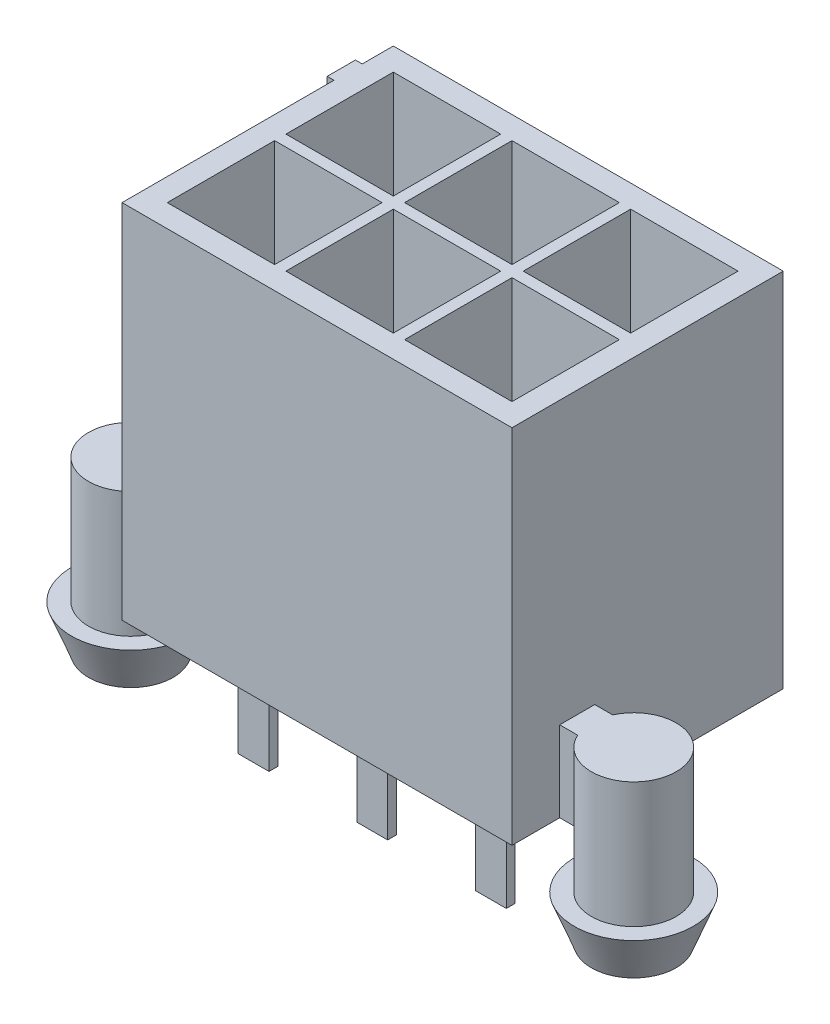
from build123d import *

# Parameters (mm, degrees)
BOSS_EXTRUDE1_DEPTH = 12.8
BOSS_EXTRUDE2_DEPTH = 2.85
SKETCH5_R           = 1.5
BOSS_EXTRUDE3_DEPTH = 3.16
SKETCH6_R           = 1.5
BOSS_EXTRUDE4_DEPTH = 1.5725
BOSS_EXTRUDE4_TAPER = -21
SKETCH9_W           = 3.8
SKETCH9_H           = 3.8
CUT_EXTRUDE3_DEPTH  = 9.2
SKETCH10_W          = 1.09
SKETCH10_H          = 1.09
BOSS_EXTRUDE6_DEPTH = 13.1
SKETCH11_W          = 3
SKETCH11_H          = 3
BOSS_EXTRUDE7_DEPTH = 1.4
CUT_EXTRUDE4_DEPTH  = 3
CUT_EXTRUDE5_DEPTH  = 1.1
LPATTERN1_COUNT     = 3
LPATTERN1_PITCH     = 4.2


with BuildPart() as part:
    # Sketch3 → Boss-Extrude1 (new body)
    with BuildSketch(Plane(origin=(0, 0, 0), x_dir=(1, 0, 0), z_dir=(0, 1, 0))):
        Polygon((13.8, 9.6), (0, 9.6), (0, 8.5), (-0.24, 8.5), (-0.24, 7.5), (0, 7.5), (0, 0), (13.8, 0), align=None)
    extrude(amount=BOSS_EXTRUDE1_DEPTH)

    # Sketch4 → Boss-Extrude2 (add)
    with BuildSketch(Plane(origin=(0, 2.85, 0), x_dir=(1, 0, 0), z_dir=(0, 1, 0))):
        with BuildLine():
            Line((0, 2.93008), (0, 1.68992))
            Line((0, 1.68992), (-0.634167, 1.68992))
            ThreePointArc((-0.634167, 1.68992), (-3.5, 2.31), (-0.634167, 2.93008))
            Line((-0.634167, 2.93008), (0, 2.93008))
        make_face()
        with BuildLine():
            Line((13.8, 2.93008), (13.8, 1.68992))
            Line((13.8, 1.68992), (14.434167, 1.68992))
            ThreePointArc((14.434167, 1.68992), (17.3, 2.31), (14.434167, 2.93008))
            Line((14.434167, 2.93008), (13.8, 2.93008))
        make_face()
    extrude(amount=-BOSS_EXTRUDE2_DEPTH)

    # Sketch5 → Boss-Extrude3 (add)
    with BuildSketch(Plane.XZ):
        with Locations((-2, -2.31)):
            Circle(SKETCH5_R)
        with Locations((15.8, -2.31)):
            Circle(SKETCH5_R)
    extrude(amount=BOSS_EXTRUDE3_DEPTH)

    # Sketch6 → Boss-Extrude4 (add)
    with BuildSketch(Plane.XZ.offset(3.16)):
        with Locations((-2, -2.31)):
            Circle(SKETCH6_R)
        with Locations((15.8, -2.31)):
            Circle(SKETCH6_R)
    extrude(amount=-BOSS_EXTRUDE4_DEPTH, taper=BOSS_EXTRUDE4_TAPER)

    # Sketch9 → Cut-Extrude3 (cut)
    with BuildSketch(Plane(origin=(0, 12.8, 0), x_dir=(1, 0, 0), z_dir=(0, 1, 0))):
        with Locations((6.9, 2.7)):
            Rectangle(SKETCH9_W, SKETCH9_H)
        with Locations((2.7, 2.7)):
            Rectangle(SKETCH9_W, SKETCH9_H)
        with Locations((11.1, 2.7)):
            Rectangle(SKETCH9_W, SKETCH9_H)
        with Locations((6.9, 6.9)):
            Rectangle(SKETCH9_W, SKETCH9_H)
        with Locations((11.1, 6.9)):
            Rectangle(SKETCH9_W, SKETCH9_H)
        with Locations((2.7, 6.9)):
            Rectangle(SKETCH9_W, SKETCH9_H)
    extrude(amount=-CUT_EXTRUDE3_DEPTH, mode=Mode.SUBTRACT)

    # Sketch11 → Boss-Extrude7 (add)
    with BuildSketch(Plane(origin=(0, 0, -9.6), x_dir=(-1, 0, 0), z_dir=(0, 0, -1))):
        with Locations((-6.9, 11.3)):
            Rectangle(SKETCH11_W, SKETCH11_H)
    extrude(amount=BOSS_EXTRUDE7_DEPTH)

    # Sketch12 → Cut-Extrude4 (cut)
    with BuildSketch(Plane.ZY.offset(-5.4)):
        Polygon((-11, 10.6), (-9.6, 12.8), (-11, 12.8), align=None)
    extrude(amount=-CUT_EXTRUDE4_DEPTH, mode=Mode.SUBTRACT)


with BuildPart() as body_2:
    # Sketch10 → Boss-Extrude6 (new body)
    with BuildSketch(Plane(origin=(0, 9.11, 0), x_dir=(-1, 0, 0), z_dir=(0, -1, 0))):
        with Locations((-2.7, 2.5)):
            Rectangle(SKETCH10_W, SKETCH10_H)
    extrude(amount=BOSS_EXTRUDE6_DEPTH)

    # Sketch13 → Cut-Extrude5 (cut)
    with BuildSketch(Plane.ZY.offset(-2.155)):
        Polygon((-2.266196, -3.99), (-2.266196, -0.327115), (-3.045, 1.768993), (-3.045, -3.99), align=None)
    extrude(amount=-CUT_EXTRUDE5_DEPTH, mode=Mode.SUBTRACT)


with BuildPart() as body_3:
    # Mirror2: mirrored copy
    add(body_2.part.mirror(Plane.XY.offset(-4.6)))


with BuildPart() as lpattern1_1:
    # LPattern1: pattern copy
    add(body_3.part.moved(Location(Vector(1, 0, 0) * (1 * LPATTERN1_PITCH))))


with BuildPart() as lpattern1_2:
    # LPattern1: pattern copy
    add(body_3.part.moved(Location(Vector(1, 0, 0) * (2 * LPATTERN1_PITCH))))


with BuildPart() as lpattern1_3:
    # LPattern1: pattern copy
    add(body_2.part.moved(Location(Vector(1, 0, 0) * (1 * LPATTERN1_PITCH))))


with BuildPart() as lpattern1_4:
    # LPattern1: pattern copy
    add(body_2.part.moved(Location(Vector(1, 0, 0) * (2 * LPATTERN1_PITCH))))


solid = Compound([part.part, body_2.part, body_3.part, lpattern1_1.part, lpattern1_2.part, lpattern1_3.part, lpattern1_4.part])
